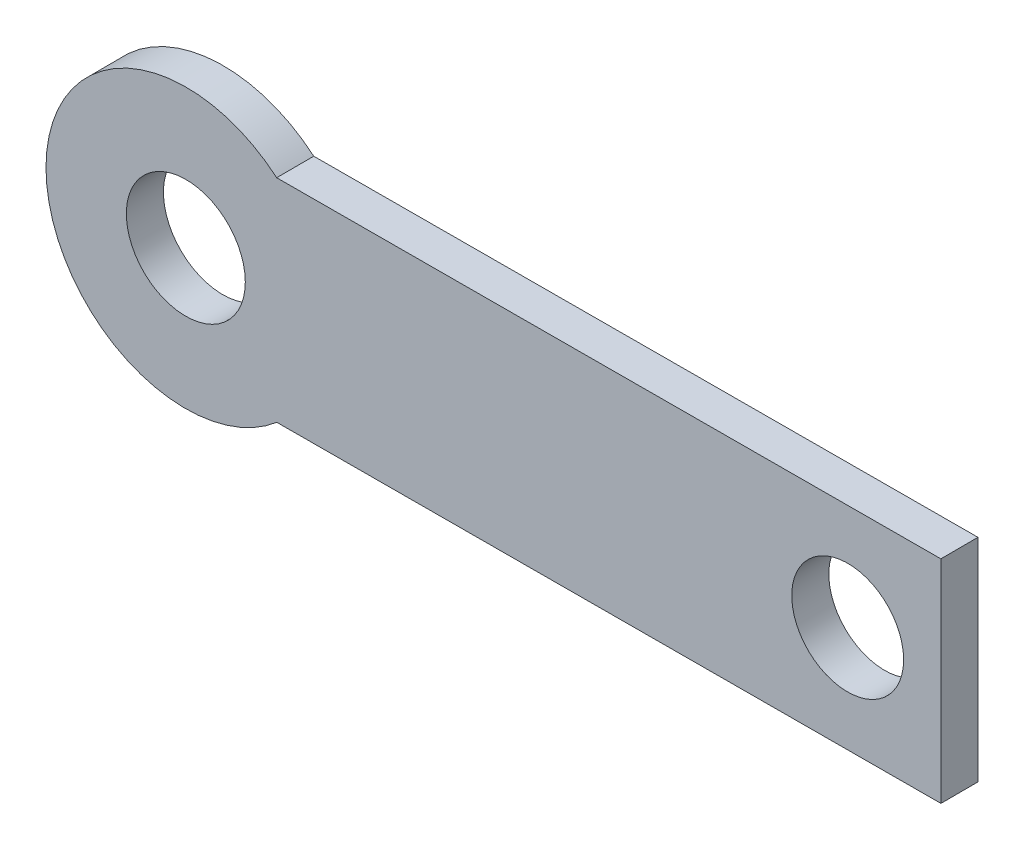
from build123d import *

# Parameters (mm, degrees)
SKETCH1_R           = 1.595
SKETCH1_R_2         = 1.5
BOSS_EXTRUDE1_DEPTH = 1


with BuildPart() as part:
    # Sketch1 → Boss-Extrude1 (new body)
    with BuildSketch(Plane(origin=(0.276968936, -0.030405965, 89.917439906), x_dir=(0.999995256, 1.042e-06, -0.003080243), z_dir=(0.003080243, -0.000338153, 0.999995199))):
        with BuildLine():
            Line((29.351122384, -23.602694705), (47.163406232, -23.602694705))
            Line((47.163406232, -23.602694705), (47.163406232, -17.90355794))
            Line((47.163406232, -17.90355794), (29.351122384, -17.90355794))
            ThreePointArc((29.351122384, -17.90355794), (23.163406232, -20.753126322), (29.351122384, -23.602694705))
        make_face()
        with Locations((26.913406232, -20.753126322)):
            Circle(SKETCH1_R, mode=Mode.SUBTRACT)
        with Locations((44.663406232, -20.753126322)):
            Circle(SKETCH1_R_2, mode=Mode.SUBTRACT)
    extrude(amount=BOSS_EXTRUDE1_DEPTH)


solid = part.part
